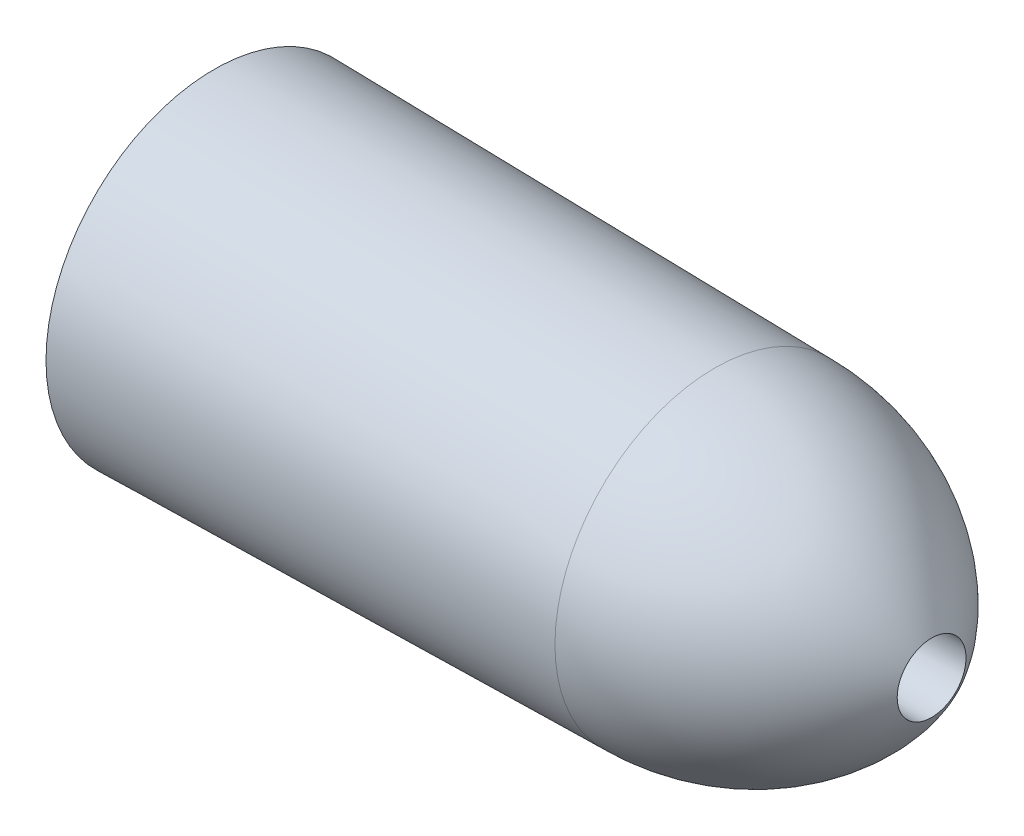
from build123d import *


with BuildPart() as part:
    # Sketch1 → Revolve1 (revolve)
    with BuildSketch(Plane(origin=(0, 0, 0), x_dir=(1, 0, 0), z_dir=(0, 1, 0))):
        Polygon((-273.05, 63.9802871), (-273.05, 12.3), (-82.55, 12.858139535), (-82.55, 60.79718825), align=None)
        with BuildLine():
            Line((-82.55, 60.79718825), (-82.55, 12.858139535))
            Line((-82.55, 12.858139535), (0, 13.1))
            ThreePointArc((0, 13.1), (-34.880501715, 48.015616161), (-82.55, 60.79718825))
        make_face()
    revolve(axis=Axis((-491.53912206, 0, 0), (1, 0, 0)))


solid = part.part
